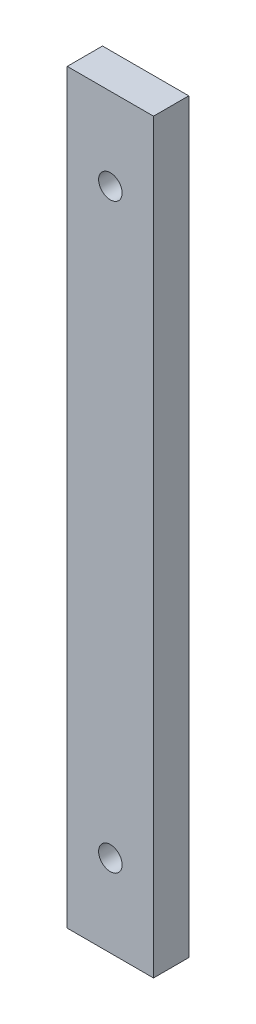
from build123d import *

# Parameters (mm, degrees)
SKETCH1_W           = 14.68
SKETCH1_H           = 127
BOSS_EXTRUDE1_DEPTH = 6
SKETCH2_R           = 2
CUT_EXTRUDE1_DEPTH  = 6


with BuildPart() as part:
    # Sketch1 → Boss-Extrude1 (new body)
    with BuildSketch(Plane.XY):
        Rectangle(SKETCH1_W, SKETCH1_H)
    extrude(amount=BOSS_EXTRUDE1_DEPTH)

    # Sketch2 → Cut-Extrude1 (cut)
    with BuildSketch(Plane.XY.offset(6)):
        with Locations((0, -49.5)):
            Circle(SKETCH2_R)
        with Locations((0, 49.5)):
            Circle(SKETCH2_R)
    extrude(amount=-CUT_EXTRUDE1_DEPTH, mode=Mode.SUBTRACT)


solid = part.part
